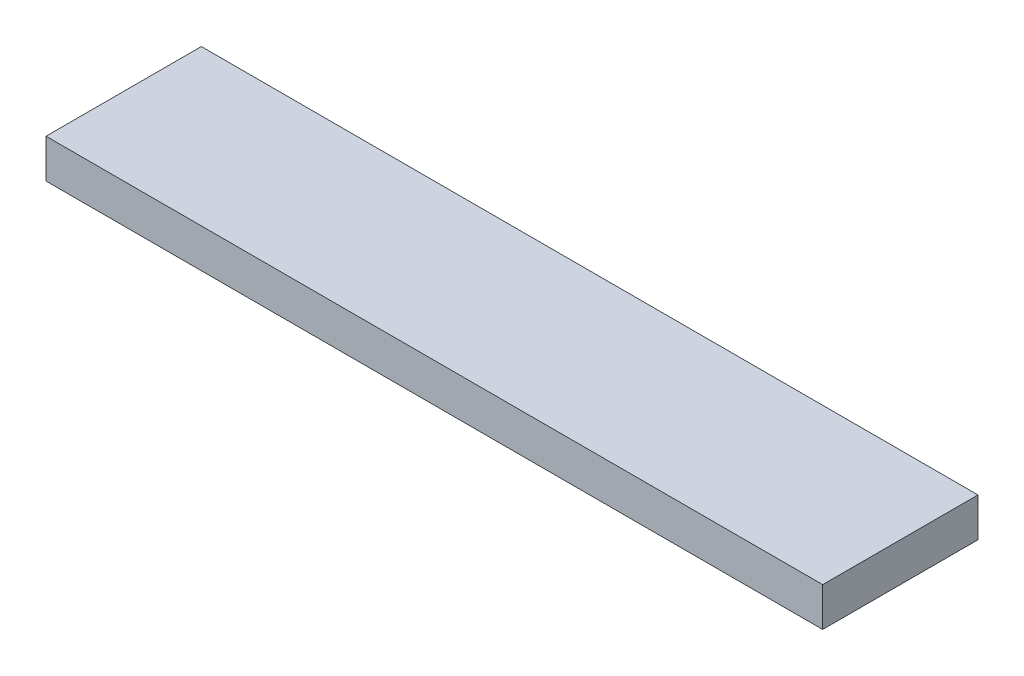
from build123d import *

# Parameters (mm, degrees)
SKETCH1_W           = 127
SKETCH1_H           = 25.4
BOSS_EXTRUDE1_DEPTH = 6.35


with BuildPart() as part:
    # Sketch1 → Boss-Extrude1 (new body)
    with BuildSketch(Plane(origin=(0, 0, 0), x_dir=(1, 0, 0), z_dir=(0, 1, 0))):
        Rectangle(SKETCH1_W, SKETCH1_H)
    extrude(amount=BOSS_EXTRUDE1_DEPTH)


solid = part.part
